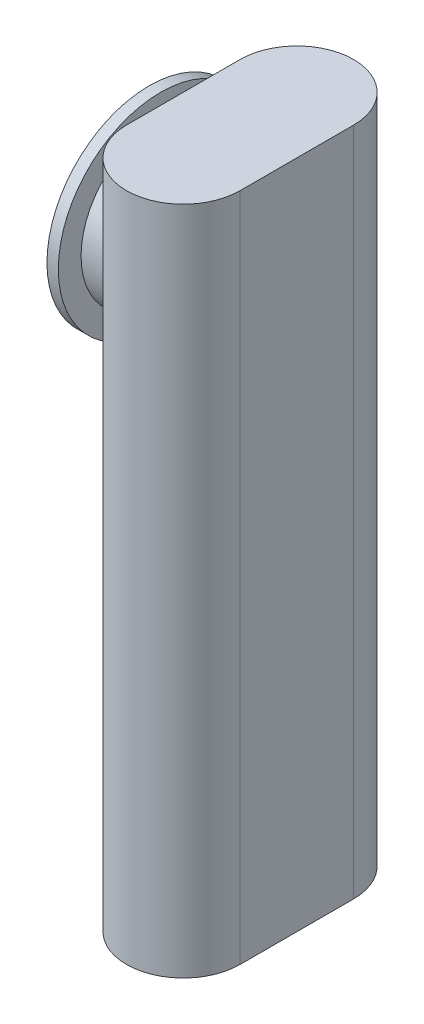
from build123d import *

# Parameters (mm, degrees)
BOSS_EXTRU_6_DEPTH      = 28
BOSS_EXTRU_7_START      = -1.5
BOSS_EXTRU_7_DEPTH      = 1.5
BOSS_EXTRU_9_DEPTH      = 1
BOSS_EXTRU_9_DEPTH_BACK = 0.5
ESQUISSE2_R             = 3.5
ESQUISSE2_R_2           = 2.5
ENL_V_MAT_EXTRU_1_DEPTH = 1.75
ENL_V_MAT_EXTRU_2_DEPTH = 25.5
BOSS_EXTRU_10_START     = 0.5
ESQUISSE3_R             = 4.5
ESQUISSE3_R_2           = 2.5
BOSS_EXTRU_10_DEPTH     = 0.5


with BuildPart() as part:
    # Esquisse1 → Boss.-Extru.6 (new body)
    with BuildSketch(Plane(origin=(0, 0, 0), x_dir=(1, 0, 0), z_dir=(0, 1, 0))):
        with BuildLine():
            ThreePointArc((-19.5, -2.5), (-17, -5), (-14.5, -2.5))
            Line((-14.5, -2.5), (-14.5, 2.5))
            ThreePointArc((-14.5, 2.5), (-17, 5), (-19.5, 2.5))
            Line((-19.5, 2.5), (-19.5, -2.5))
        make_face()
    extrude(amount=BOSS_EXTRU_6_DEPTH)

    # Esquisse1_12 → Boss.-Extru.7 (add)
    with BuildSketch(Plane(origin=(0, 0, 0), x_dir=(1, 0, 0), z_dir=(0, 1, 0)).offset(BOSS_EXTRU_7_START)):
        with BuildLine():
            ThreePointArc((-19.5, -2.5), (-17, -5), (-14.5, -2.5))
            Line((-14.5, -2.5), (-14.5, 2.5))
            ThreePointArc((-14.5, 2.5), (-17, 5), (-19.5, 2.5))
            Line((-19.5, 2.5), (-19.5, -2.5))
        make_face()
        with BuildLine():
            Line((-19, -2.5), (-19, 2.5))
            ThreePointArc((-19, 2.5), (-17, 4.5), (-15, 2.5))
            Line((-15, 2.5), (-15, -2.5))
            ThreePointArc((-15, -2.5), (-17, -4.5), (-19, -2.5))
        make_face(mode=Mode.SUBTRACT)
    extrude(amount=BOSS_EXTRU_7_DEPTH)

    # Esquisse2_5 → Enl_v. mat.-Extru.1 (cut)
    with BuildSketch(Plane.ZY.offset(19.5)):
        with BuildLine():
            ThreePointArc((2.5, 23), (1.767766953, 24.767766953), (0, 25.5))
            ThreePointArc((0, 25.5), (-1.767766953, 21.232233047), (2.5, 23))
        make_face()
    extrude(amount=-ENL_V_MAT_EXTRU_1_DEPTH, mode=Mode.SUBTRACT)

    # Esquisse1_17 → Enl_v. mat.-Extru.2 (cut)
    with BuildSketch(Plane(origin=(0, 0, 0), x_dir=(1, 0, 0), z_dir=(0, 1, 0))):
        with BuildLine():
            ThreePointArc((-19, -2.5), (-17, -4.5), (-15, -2.5))
            Line((-15, -2.5), (-15, 2.5))
            ThreePointArc((-15, 2.5), (-17, 4.5), (-19, 2.5))
            Line((-19, 2.5), (-19, -2.5))
        make_face()
    extrude(amount=ENL_V_MAT_EXTRU_2_DEPTH, mode=Mode.SUBTRACT)


with BuildPart() as body_2:
    # Esquisse2 → Boss.-Extru.9 (new, two sides: drawn at the far end of the back side and taken through both)
    with BuildSketch(Plane.ZY.offset(19.5).offset(-BOSS_EXTRU_9_DEPTH_BACK)):
        with Locations((0, 23)):
            Circle(ESQUISSE2_R)
        with Locations((0, 23)):
            Circle(ESQUISSE2_R_2, mode=Mode.SUBTRACT)
    extrude(amount=BOSS_EXTRU_9_DEPTH + BOSS_EXTRU_9_DEPTH_BACK)

    # Esquisse3 → Boss.-Extru.10 (add)
    with BuildSketch(Plane.ZY.offset(20.5).offset(BOSS_EXTRU_10_START)):
        with Locations((0, 23)):
            Circle(ESQUISSE3_R)
        with Locations((0, 23)):
            Circle(ESQUISSE3_R_2, mode=Mode.SUBTRACT)
    extrude(amount=-BOSS_EXTRU_10_DEPTH)


solid = Compound([part.part, body_2.part])
